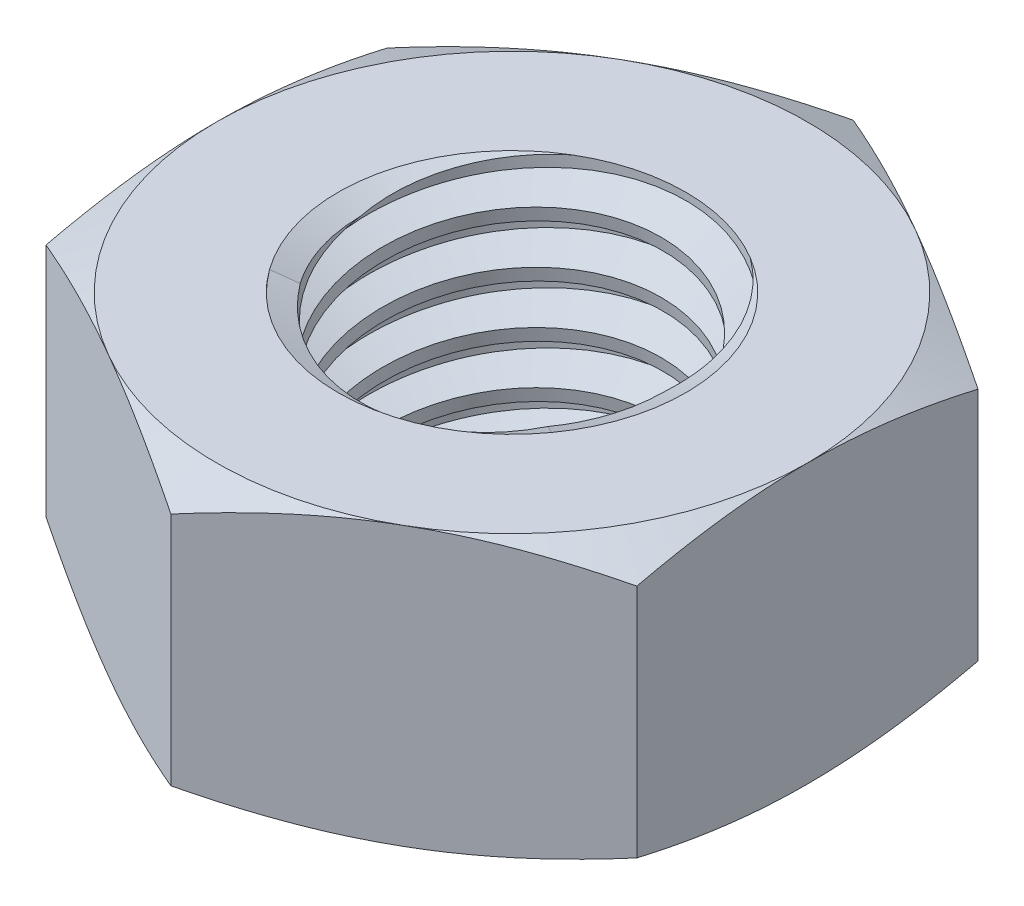
from build123d import *

# Parameters (mm, degrees)
EXTRUDE1_DEPTH       = 4
SKETCH2_W            = 5
SKETCH2_H            = 8
LPATTERN1_COUNT      = 5
LPATTERN1_PITCH      = 1.5
LPATTERN1_COUNT_DIR2 = 2
LPATTERN1_PITCH_DIR2 = 1.5


with BuildPart() as part:
    # Sketch1 → Extrude1 (new, symmetric)
    with BuildSketch(Plane(origin=(0, 0, 0), x_dir=(1, 0, 0), z_dir=(0, 1, 0))):
        Polygon((0, 9.814954576), (-8.5, 4.907477288), (-8.5, -4.907477288), (0, -9.814954576), (8.5, -4.907477288), (8.5, 4.907477288), align=None)
    extrude(amount=EXTRUDE1_DEPTH, both=True)

    # Sketch4 → Cut-Revolve2 (revolve, cut)
    with BuildSketch(Plane(origin=(0, 0, 0), x_dir=(0, 0, -1), z_dir=(1, 0, 0))):
        Polygon((0, 4), (5, 4), (4.294432168, 3.670988317), (4.294432168, -3.670988317), (5, -4), (0, -4), align=None)
    revolve(axis=Axis((0, 4, 0), (0, 1, 0)), mode=Mode.SUBTRACT)


with BuildPart() as body_2:
    # Sketch2 → Revolve1 (revolve)
    with BuildSketch(Plane(origin=(0, 0, 0), x_dir=(0, 0, -1), z_dir=(1, 0, 0))):
        with Locations((2.5, 0)):
            Rectangle(SKETCH2_W, SKETCH2_H)
    revolve(axis=Axis((0, -9, 0), (0, 1, 0)))

    # Sketch3 → Cut-Revolve1 (revolve, cut)
    with BuildSketch(Plane(origin=(0, 0, 0), x_dir=(0, 0, -1), z_dir=(1, 0, 0))):
        Polygon((5.027813835, 3.814574434), (5.222510679, 2.516595471), (4.350059838, 2.859721948), (4.294432168, 3.23057308), align=None)
    cut_revolve1 = revolve(axis=Axis((0, 4, 0.240478408), (0, -0.9889363528682975, -0.14834045293024486)), mode=Mode.SUBTRACT)

    # LPattern1: Cut-Revolve1 5 × 2
    with Locations(*[Vector(0, -1, 0) * (i * LPATTERN1_PITCH) + Vector(0, 1, 0) * (j * LPATTERN1_PITCH_DIR2) for i in range(LPATTERN1_COUNT) for j in range(LPATTERN1_COUNT_DIR2) if (i, j) != (0, 0)]):
        add(cut_revolve1, mode=Mode.SUBTRACT)


with BuildPart() as part_1:
    add(part.part)

    # Combine1: cut body 2
    add(body_2.part, mode=Mode.SUBTRACT)

    # Sketch5 → Cut-Revolve3 (revolve, cut)
    with BuildSketch(Plane(origin=(0, 0, 0), x_dir=(0, 0, -1), z_dir=(1, 0, 0))):
        Polygon((0, -4), (8.5, -4), (9.814954576, -3.386826611), (9.814954576, 3.386826611), (8.5, 4), (0, 4), (0, 5.27), (11.084954576, 5.27), (11.084954576, -5.27), (0, -5.27), align=None)
    revolve(axis=Axis((0, -4, 0), (0, 1, 0)), mode=Mode.SUBTRACT)


solid = part_1.part
